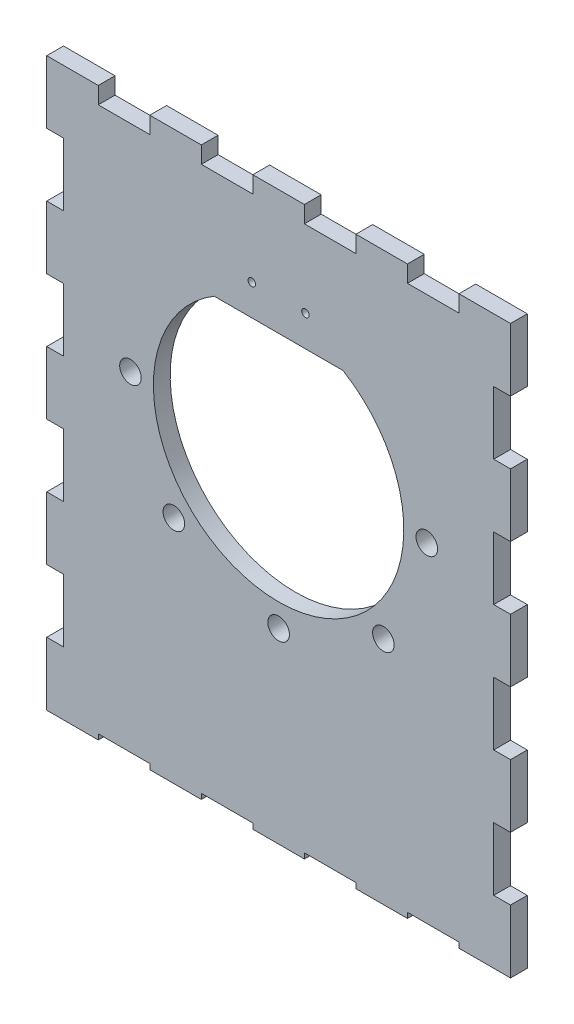
from build123d import *

# Parameters (mm, degrees)
SKETCH1_W           = 137.16
SKETCH1_H           = 167.64
BOSS_EXTRUDE1_DEPTH = 4.9609375
CUT_EXTRUDE1_DEPTH  = 5.9609375
SKETCH4_R           = 3.1877
CUT_EXTRUDE2_DEPTH  = 5.9609375
SKETCH6_W           = 4.9634902
SKETCH6_H           = 18.6182
SKETCH6_W_2         = 15.24
SKETCH6_H_2         = 4.9634902
SKETCH6_H_3         = 1.5875
CUT_EXTRUDE5_DEPTH  = 5.9609375
SKETCH7_OUTSIDE_W   = 182.492
SKETCH7_OUTSIDE_H   = 212.972
SKETCH7_OUTSIDE_R   = 1.1049
CUT_EXTRUDE6_DEPTH  = 5.9609375


with BuildPart() as part:
    # Sketch1 → Boss-Extrude1 (new body)
    with BuildSketch(Plane.XY):
        with Locations((0, -15.24)):
            Rectangle(SKETCH1_W, SKETCH1_H)
    extrude(amount=BOSS_EXTRUDE1_DEPTH)

    # Sketch2 → Cut-Extrude1 (cut, through all)
    with BuildSketch(Plane.XY.offset(4.9609375)):
        with BuildLine():
            Line((-19.05, 31.75), (19.05, 31.75))
            ThreePointArc((19.05, 31.75), (0, -37.026544532), (-19.05, 31.75))
        make_face()
    extrude(amount=-CUT_EXTRUDE1_DEPTH, mode=Mode.SUBTRACT)

    # Sketch4 → Cut-Extrude2 (cut, through all)
    with BuildSketch(Plane.XY.offset(4.9609375)):
        with Locations((-43.815, 0)):
            Circle(SKETCH4_R)
        with Locations((-30.981883618, -30.981883618)):
            Circle(SKETCH4_R)
        with Locations((0, -43.815)):
            Circle(SKETCH4_R)
        with Locations((30.981883618, -30.981883618)):
            Circle(SKETCH4_R)
        with Locations((43.815, 0)):
            Circle(SKETCH4_R)
    extrude(amount=-CUT_EXTRUDE2_DEPTH, mode=Mode.SUBTRACT)

    # Sketch6 → Cut-Extrude5 (cut, through all)
    with BuildSketch(Plane.XY.offset(4.9609375)):
        with Locations((-66.0982549, 3.4163)):
            Rectangle(SKETCH6_W, SKETCH6_H)
        with Locations((-66.0982549, 40.6527)):
            Rectangle(SKETCH6_W, SKETCH6_H)
        with Locations((-66.0982549, -33.8201)):
            Rectangle(SKETCH6_W, SKETCH6_H)
        with Locations((-66.0982549, -71.0565)):
            Rectangle(SKETCH6_W, SKETCH6_H)
        with Locations((66.0982549, 3.40868)):
            Rectangle(SKETCH6_W, SKETCH6_H)
        with Locations((66.0982549, 40.64508)):
            Rectangle(SKETCH6_W, SKETCH6_H)
        with Locations((66.0982549, -33.82772)):
            Rectangle(SKETCH6_W, SKETCH6_H)
        with Locations((66.0982549, -71.06412)):
            Rectangle(SKETCH6_W, SKETCH6_H)
        with Locations((-15.24, 66.0982549)):
            Rectangle(SKETCH6_W_2, SKETCH6_H_2)
        with Locations((-45.72, 66.0982549)):
            Rectangle(SKETCH6_W_2, SKETCH6_H_2)
        with Locations((15.24, 66.0982549)):
            Rectangle(SKETCH6_W_2, SKETCH6_H_2)
        with Locations((45.72, 66.0982549)):
            Rectangle(SKETCH6_W_2, SKETCH6_H_2)
        with Locations((-15.24, -98.26625)):
            Rectangle(SKETCH6_W_2, SKETCH6_H_3)
        with Locations((-45.72, -98.26625)):
            Rectangle(SKETCH6_W_2, SKETCH6_H_3)
        with Locations((15.24, -98.26625)):
            Rectangle(SKETCH6_W_2, SKETCH6_H_3)
        with Locations((45.72, -98.26625)):
            Rectangle(SKETCH6_W_2, SKETCH6_H_3)
    extrude(amount=-CUT_EXTRUDE5_DEPTH, mode=Mode.SUBTRACT)

    # Sketch7 outside → Cut-Extrude6 (cut, through all)
    with BuildSketch(Plane.XY.offset(4.9609375)):
        with Locations((0, -15.24)):
            Rectangle(SKETCH7_OUTSIDE_W, SKETCH7_OUTSIDE_H)
        Polygon((-63.6165098, 49.9618), (-63.6165098, 31.3436), (-68.58, 31.3436), (-68.58, 12.7254), (-63.6165098, 12.7254), (-63.6165098, -5.8928), (-68.58, -5.8928), (-68.58, -24.511), (-63.6165098, -24.511), (-63.6165098, -43.1292), (-68.58, -43.1292), (-68.58, -61.7474), (-63.6165098, -61.7474), (-63.6165098, -80.3656), (-68.58, -80.3656), (-68.58, -99.06), (-53.34, -99.06), (-53.34, -97.4725), (-38.1, -97.4725), (-38.1, -99.06), (-22.86, -99.06), (-22.86, -97.4725), (-7.62, -97.4725), (-7.62, -99.06), (7.62, -99.06), (7.62, -97.4725), (22.86, -97.4725), (22.86, -99.06), (38.1, -99.06), (38.1, -97.4725), (53.34, -97.4725), (53.34, -99.06), (68.58, -99.06), (68.58, -80.37322), (63.6165098, -80.37322), (63.6165098, -61.75502), (68.58, -61.75502), (68.58, -43.13682), (63.6165098, -43.13682), (63.6165098, -24.51862), (68.58, -24.51862), (68.58, -5.90042), (63.6165098, -5.90042), (63.6165098, 12.71778), (68.58, 12.71778), (68.58, 31.33598), (63.6165098, 31.33598), (63.6165098, 49.95418), (68.58, 49.95418), (68.58, 68.58), (53.34, 68.58), (53.34, 63.6165098), (38.1, 63.6165098), (38.1, 68.58), (22.86, 68.58), (22.86, 63.6165098), (7.62, 63.6165098), (7.62, 68.58), (-7.62, 68.58), (-7.62, 63.6165098), (-22.86, 63.6165098), (-22.86, 68.58), (-38.1, 68.58), (-38.1, 63.6165098), (-53.34, 63.6165098), (-53.34, 68.58), (-68.58, 68.58), (-68.58, 49.9618), align=None, mode=Mode.SUBTRACT)
        with Locations((-7.9375, 40.87749)):
            Circle(SKETCH7_OUTSIDE_R)
        with Locations((7.9375, 40.87749)):
            Circle(SKETCH7_OUTSIDE_R)
    extrude(amount=-CUT_EXTRUDE6_DEPTH, mode=Mode.SUBTRACT)


solid = part.part
